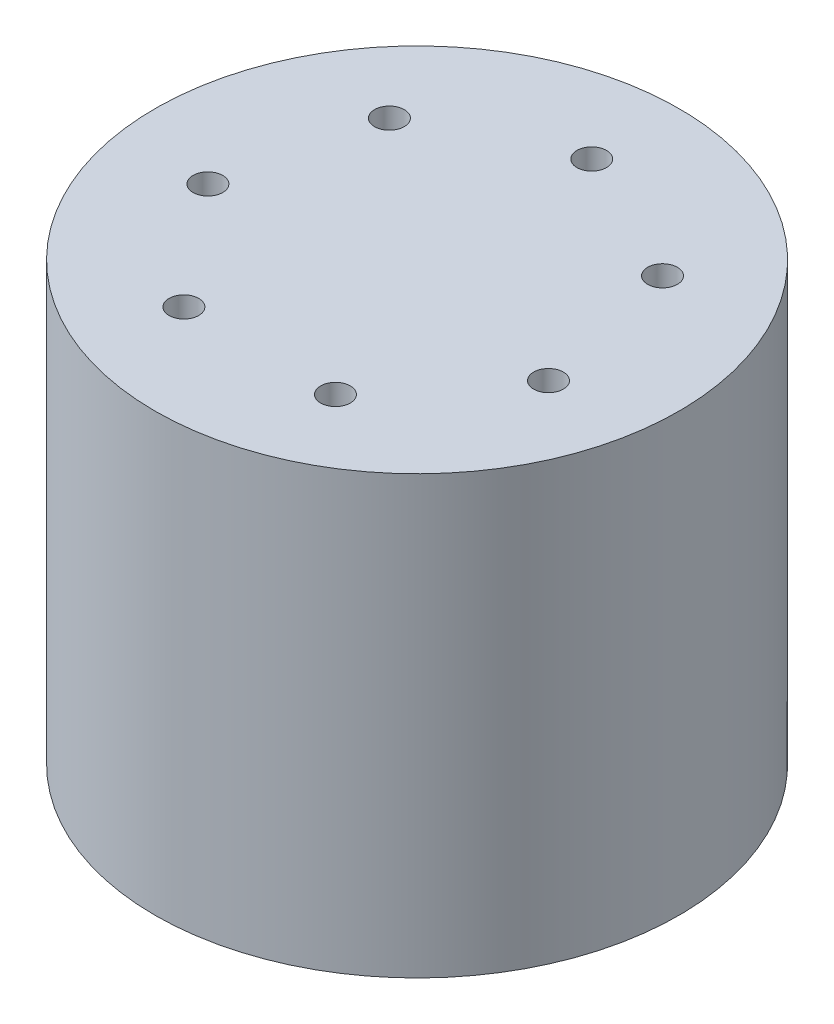
from build123d import *

# Parameters (mm, degrees)
SKETCH_1_R             = 60
EXTRUDE_1_DEPTH        = 100
HOLE_WIZARD_M8_1_D     = 6.8
HOLE_WIZARD_M8_1_DEPTH = 22.25
HOLE_WIZARD_M8_1_TIP   = 2.042926105


with BuildPart() as part:
    # 草圖1 → 填料-伸長1 (new body)
    with BuildSketch(Plane(origin=(0, 0, 0), x_dir=(1, 0, 0), z_dir=(0, 1, 0))):
        Circle(SKETCH_1_R)
    extrude(amount=EXTRUDE_1_DEPTH)

    # M8 螺紋孔1
    with Locations(Plane(origin=(0, 100, -40), x_dir=(0, 0, 1), z_dir=(0, 1, 0))):
        with Locations((0, 0), (15.060407926, 31.273259299), (48.900837358, 38.997116487), (76.038754716, 17.355349565), (76.038754716, -17.355349565), (48.900837358, -38.997116487), (15.060407926, -31.273259299)):
            Hole(HOLE_WIZARD_M8_1_D / 2, depth=HOLE_WIZARD_M8_1_DEPTH)
            with Locations((0, 0, -(HOLE_WIZARD_M8_1_DEPTH + HOLE_WIZARD_M8_1_TIP / 2))):  # 118° drill point
                Cone(0, HOLE_WIZARD_M8_1_D / 2, HOLE_WIZARD_M8_1_TIP, mode=Mode.SUBTRACT)


solid = part.part
